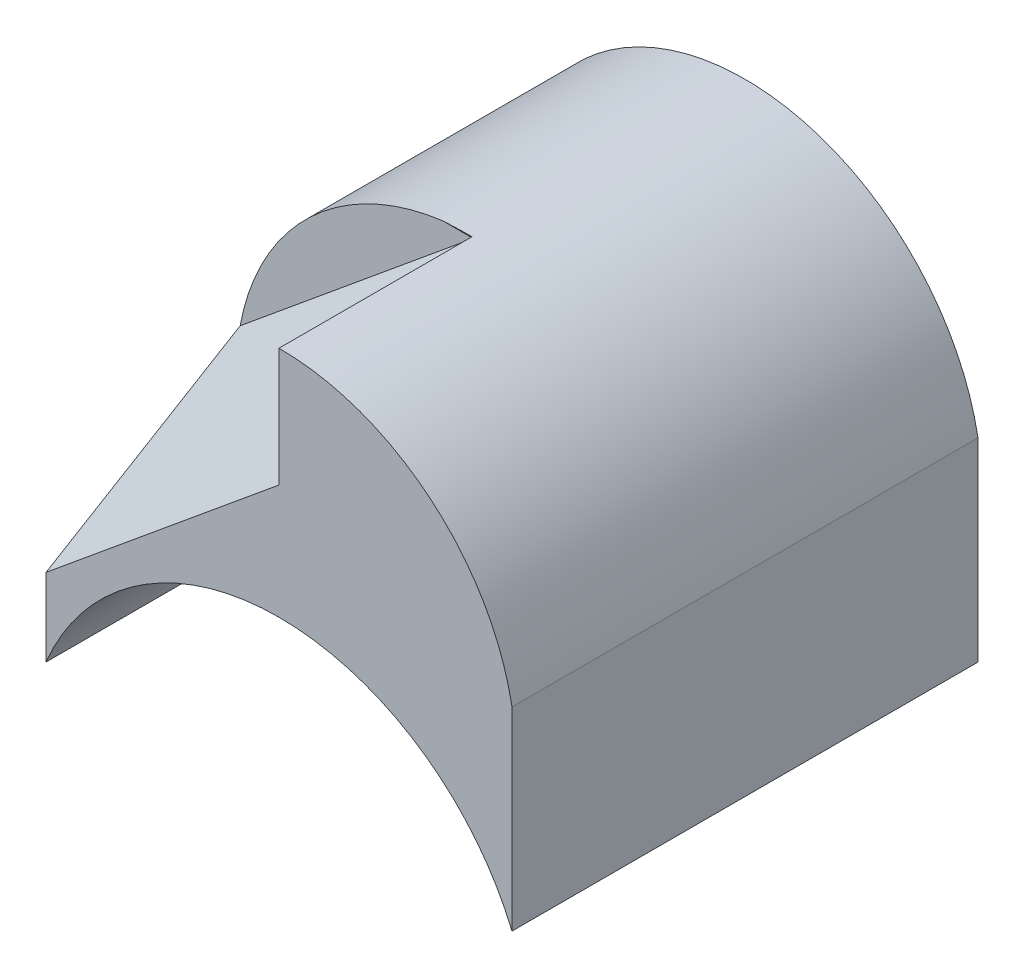
from build123d import *

# Parameters (mm, degrees)
SKETCH1_W           = 6
SKETCH1_H           = 6
BOSS_EXTRUDE1_DEPTH = 5
CUT_EXTRUDE4_DEPTH  = 12.5
CUT_EXTRUDE5_DEPTH  = 10
CUT_EXTRUDE6_DEPTH  = 10


with BuildPart() as part:
    # Sketch1 → Boss-Extrude1 (new body)
    with BuildSketch(Plane(origin=(0, 0, 0), x_dir=(1, 0, 0), z_dir=(0, 1, 0))):
        Rectangle(SKETCH1_W, SKETCH1_H)
    extrude(amount=BOSS_EXTRUDE1_DEPTH)

    # Sketch5 → Cut-Extrude4 (cut)
    with BuildSketch(Plane.XY.offset(3)):
        with BuildLine():
            Line((-3, 5), (-3, 2.5))
            ThreePointArc((-3, 2.5), (-1.952562419, 4.293074903), (0, 5))
            Line((0, 5), (-3, 5))
        make_face()
        with BuildLine():
            ThreePointArc((0, 5), (1.952562419, 4.293074903), (3, 2.5))
            Line((3, 2.5), (3, 5))
            Line((3, 5), (0, 5))
        make_face()
        with BuildLine():
            ThreePointArc((-3, 0), (0, 2), (3, 0))
            Line((3, 0), (-3, 0))
        make_face()
    extrude(amount=-CUT_EXTRUDE4_DEPTH, mode=Mode.SUBTRACT)

    # 3DSketch1 → Cut-Extrude5 (cut, along a direction that is not the sketch's normal)
    with BuildSketch(Plane(origin=(-3, 1, 3), x_dir=(0.5383808129093879, 0.7133433044036882, -0.4486506774244899), z_dir=(0.5775173034874745, -0.700038740615242, -0.4200232443691449))):
        Polygon((0, 0), (2.19164165, -1.922682209), (5.572263959, 0), (3.380622309, 1.922682209), align=None)
    extrude(amount=-CUT_EXTRUDE5_DEPTH, dir=(1, 0, 0), mode=Mode.SUBTRACT)

    # Sketch7 → Cut-Extrude6 (cut)
    with BuildSketch(Plane(origin=(0, 3.878630283, 2.32717817), x_dir=(1, 0, 0), z_dir=(0, -0.8574929257125444, -0.5144957554275263))):
        with BuildLine():
            Line((-0.390198698, -2.130837603), (0, -2.130837603))
            Line((0, -2.130837603), (0, 0.784638345))
            Line((0, 0.784638345), (-2.641413746, 0.784638345))
            add(Edge.make_bspline(
                [(-2.641413746, 0.784638345), (-1.886895872, -1.755586828), (-0.390198698, -2.130837603)],
                knots=[2.094371322, 2.094371322, 2.094371322, 3.013307074, 3.013307074, 3.013307074], degree=2, weights=[1, 0.896288606, 1]))
        make_face()
    extrude(amount=-CUT_EXTRUDE6_DEPTH, mode=Mode.SUBTRACT)


solid = part.part
